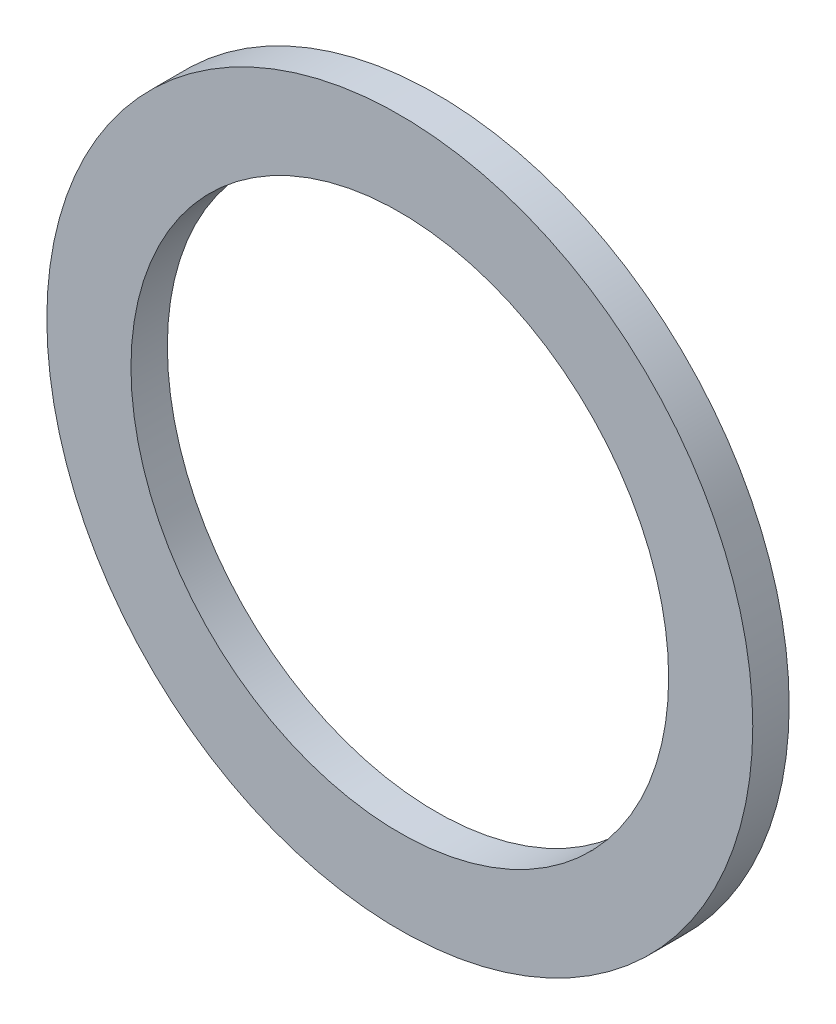
from build123d import *

# Parameters (mm, degrees)
SKETCH1_R           = 7.8867
SKETCH1_R_2         = 6.0071
BOSS_EXTRUDE1_DEPTH = 0.8128


with BuildPart() as part:
    # Sketch1 → Boss-Extrude1 (new body)
    with BuildSketch(Plane.XY):
        Circle(SKETCH1_R)
        Circle(SKETCH1_R_2, mode=Mode.SUBTRACT)
    extrude(amount=BOSS_EXTRUDE1_DEPTH)


solid = part.part
